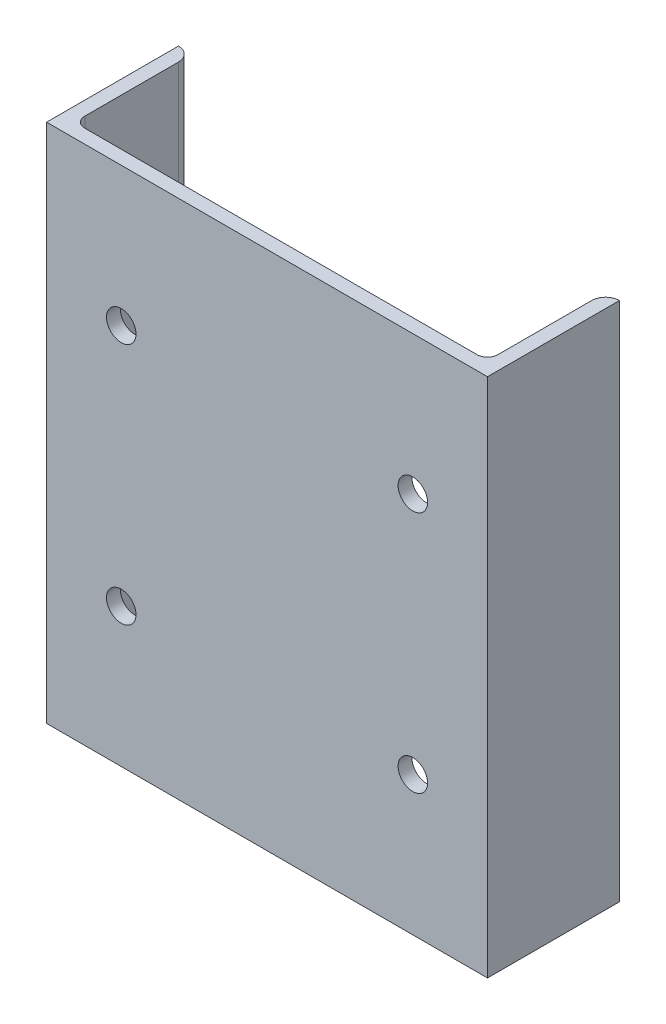
from build123d import *

# Parameters (mm, degrees)
EXTRUDE1_DEPTH     = 150
CUT_EXTRUDE1_REACH = 78
SKETCH2_R          = 8.5


with BuildPart() as part:
    # Sketch1 → Extrude1 (new body, symmetric)
    with BuildSketch(Plane(origin=(0, 0, 0), x_dir=(1, 0, 0), z_dir=(0, 1, 0))):
        with BuildLine():
            Line((-127, 0), (127, 0))
            Line((127, 0), (127, 76))
            ThreePointArc((127, 76), (121.343145751, 73.656854249), (119, 68))
            Line((119, 68), (119, 14))
            ThreePointArc((119, 14), (117.242640687, 9.757359313), (113, 8))
            Line((113, 8), (-113, 8))
            ThreePointArc((-113, 8), (-117.242640687, 9.757359313), (-119, 14))
            Line((-119, 14), (-119, 68))
            ThreePointArc((-119, 68), (-121.343145751, 73.656854249), (-127, 76))
            Line((-127, 76), (-127, 0))
        make_face()
    extrude(amount=EXTRUDE1_DEPTH, both=True)

    # Sketch2 → Cut-Extrude1 (cut, up to next)
    with BuildSketch(Plane.XY, mode=Mode.PRIVATE) as cut_extrude1_sk1:
        with Locations((84, 70)):
            Circle(SKETCH2_R)
    cut_extrude1_tool1 = extrude(cut_extrude1_sk1.sketch, amount=-CUT_EXTRUDE1_REACH, mode=Mode.PRIVATE) & part.part
    add(cut_extrude1_tool1.solids().sort_by_distance((84, 70, 0))[0], mode=Mode.SUBTRACT)
    # Sketch2 → Cut-Extrude1 (cut, up to next)
    with BuildSketch(Plane.XY, mode=Mode.PRIVATE) as cut_extrude1_sk2:
        with Locations((-84, 70)):
            Circle(SKETCH2_R)
    cut_extrude1_tool2 = extrude(cut_extrude1_sk2.sketch, amount=-CUT_EXTRUDE1_REACH, mode=Mode.PRIVATE) & part.part
    add(cut_extrude1_tool2.solids().sort_by_distance((-84, 70, 0))[0], mode=Mode.SUBTRACT)
    # Sketch2 → Cut-Extrude1 (cut, up to next)
    with BuildSketch(Plane.XY, mode=Mode.PRIVATE) as cut_extrude1_sk3:
        with Locations((-84, -70)):
            Circle(SKETCH2_R)
    cut_extrude1_tool3 = extrude(cut_extrude1_sk3.sketch, amount=-CUT_EXTRUDE1_REACH, mode=Mode.PRIVATE) & part.part
    add(cut_extrude1_tool3.solids().sort_by_distance((-84, -70, 0))[0], mode=Mode.SUBTRACT)
    # Sketch2 → Cut-Extrude1 (cut, up to next)
    with BuildSketch(Plane.XY, mode=Mode.PRIVATE) as cut_extrude1_sk4:
        with Locations((84, -70)):
            Circle(SKETCH2_R)
    cut_extrude1_tool4 = extrude(cut_extrude1_sk4.sketch, amount=-CUT_EXTRUDE1_REACH, mode=Mode.PRIVATE) & part.part
    add(cut_extrude1_tool4.solids().sort_by_distance((84, -70, 0))[0], mode=Mode.SUBTRACT)


solid = part.part
